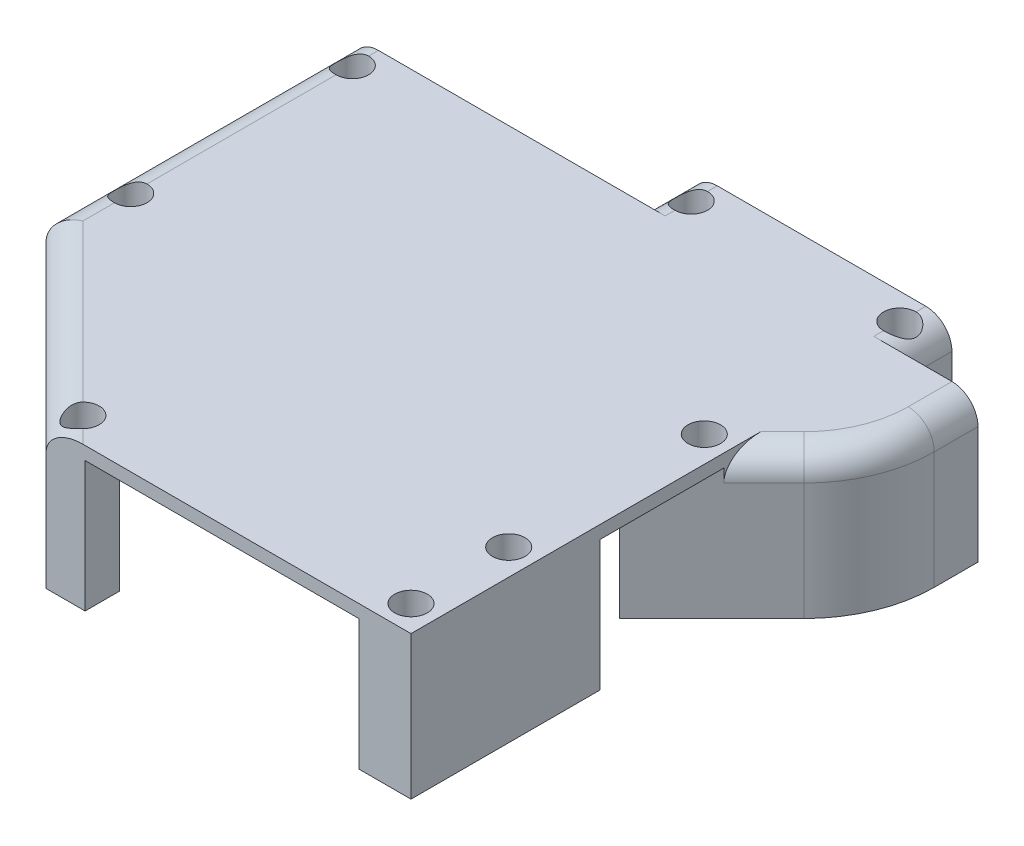
from build123d import *

# Parameters (mm, degrees)
BOSS_EXTRUDE2_DEPTH   = 11
BOSS_EXTRUDE2_2_DEPTH = 11
BOSS_EXTRUDE3_START   = 11
BOSS_EXTRUDE3_DEPTH   = 1
FILLET2_R             = 10
FILLET1_R             = 2
BOSS_EXTRUDE4_DEPTH   = 11
TUBE_HOLES_DEPTH      = 10
POT_INSERT_DEPTH      = 2.5
POT_START             = -2.5
SKETCH13_R            = 2.75
POT_HOLE_DEPTH        = 1.5
SKETCH7_R             = 0.8
SCREW_HOLES_DEPTH     = 12
SCREW_START           = 11
SKETCH12_R            = 1.25
SCREW_HEADS_DEPTH     = 3


with BuildPart() as part:
    # Sketch3 → Boss-Extrude2 (new body)
    with BuildSketch(Plane(origin=(0, 0, 0), x_dir=(1, 0, 0), z_dir=(0, 1, 0))):
        Polygon((-2.631461599, 29.291458176), (-6.631461599, 29.291458176), (-6.631461599, 5.791458176), (7.368538401, -8.208541824), (35.368538401, -8.208541824), (35.368538401, 15.791458176), (41.368538401, 21.791458176), (41.368538401, 29.291458179), (35.368538401, 29.291458179), (35.368538401, 33.291458176), (31.368538401, 33.291458176), (31.368538401, 29.291458176), (34.368538401, 29.291458176), (34.368538401, 28.291458176), (39.368538401, 28.291458176), (39.368538401, 22.619885301), (35.040111276, 18.291458176), (31.368538401, 18.291458176), (31.368538401, 11.791458176), (34.368538401, 14.791458176), (34.368538401, 5.306176806), (31.368538401, 2.306176806), (31.368538401, -0.708541824), (34.368538401, -0.708541824), (34.368538401, -4.208541824), (31.368538401, -4.208541824), (31.368538401, -7.208541824), (12.02539265, -7.208541824), (-2.631461599, 7.448312426), (-2.631461599, 12.291458176), (-5.631461599, 12.291458176), (-5.631461599, 25.291458176), (-2.631461599, 25.291458176), align=None)
    extrude(amount=BOSS_EXTRUDE2_DEPTH)



with BuildPart() as body_2:
    # Sketch3 → Boss-Extrude2 2 (new body)
    with BuildSketch(Plane(origin=(0, 0, 0), x_dir=(1, 0, 0), z_dir=(0, 1, 0))):
        Polygon((9.368538401, 29.291458176), (15.368538401, 29.291458176), (15.368538401, 33.291458176), (19.368538401, 33.291458176), (19.368538401, 28.291458176), (9.368538401, 28.291458176), align=None)
    extrude(amount=BOSS_EXTRUDE2_2_DEPTH)


with BuildPart() as part_1:
    add(part.part)

    add(body_2.part)  # Boss-Extrude3 merges body 2
    # Sketch5 → Boss-Extrude3 (add)
    with BuildSketch(Plane(origin=(0, 0, 0), x_dir=(1, 0, 0), z_dir=(0, 1, 0)).offset(BOSS_EXTRUDE3_START)):
        Polygon((-6.631461599, 29.291458176), (15.368538401, 29.291458176), (15.368538401, 33.291458176), (35.368538401, 33.291458176), (35.368538401, 29.291458179), (41.368538401, 29.291458179), (41.368538401, 21.791458176), (35.368538401, 15.791458176), (35.368538401, -8.208541824), (7.368538401, -8.208541824), (-6.631461599, 5.791458176), align=None)
    extrude(amount=-BOSS_EXTRUDE3_DEPTH)

    # Fillet2
    fillet2_edges = [part_1.edges().sort_by_distance(p)[0] for p in [
        (41.368538401, 5.5, -21.791458176),
    ]]
    fillet(fillet2_edges, radius=FILLET2_R)

    # Fillet1
    fillet1_edges = [part_1.edges().sort_by_distance(p)[0] for p in [
        (36.904072307, 11, -17.326992082),
        (41.368538401, 11, -27.61252599),
        (35.368538401, 11, -31.291458178),
        (15.368538401, 11, -31.291458176),
        (40.607333726, 11, -22.106759476),
        (-6.631461599, 11, -17.541458176),
        (0.368538401, 11, 1.208541824),
    ]]
    fillet(fillet1_edges, radius=FILLET1_R)

    # Sketch14 → Boss-Extrude4 (add)
    with BuildSketch(Plane(origin=(0, 0, 0), x_dir=(1, 0, 0), z_dir=(0, 1, 0))):
        Polygon((31.368538401, 11.791458176), (35.368538401, 15.791458176), (35.368538401, 17.791458176), (31.368538401, 13.791458176), align=None)
    extrude(amount=BOSS_EXTRUDE4_DEPTH)

    # Sketch10 → Tube Holes (cut)
    with BuildSketch(Plane(origin=(0, 0, 0), x_dir=(1, 0, 0), z_dir=(0, 1, 0))):
        Polygon((34.368538401, 5.306176806), (35.368538401, 6.306176806), (35.368538401, 15.791458176), (34.368538401, 14.791458176), align=None)
        Polygon((10.368538401, -5.551687574), (10.368538401, -8.208541824), (31.368538401, -8.208541824), (31.368538401, -3.516153668), (17.52539265, -3.516153668), (6.918790933, 7.09044805), (2.322596855, 2.494253972), align=None)
    extrude(amount=TUBE_HOLES_DEPTH, mode=Mode.SUBTRACT)

    # Sketch9 → Pot Insert (cut)
    with BuildSketch(Plane(origin=(-0.420001711, 0, 0.420001711), x_dir=(0.707106781, 0, 0.707106781), z_dir=(-0.707106781, 0, 0.707106781))):
        Polygon((-8.284330815, 0), (-8.284330815, -1.5), (-6.784330815, -4.5), (-6.784330815, -5.5), (-2.784330815, -5.5), (1.465669185, -5.5), (1.465669185, -4.5), (6.715669185, -4.5), (6.715669185, 0), align=None)
        Polygon((-8.284330815, 1.5), (-8.284330815, 0), (6.715669185, 0), (6.715669185, 4.5), (1.465669185, 4.5), (1.465669185, 5.5), (-2.784330815, 5.5), (-6.784330815, 5.5), (-6.784330815, 4.5), align=None)
    extrude(amount=-POT_INSERT_DEPTH, mode=Mode.SUBTRACT)

    # Sketch13 → Pot Hole (cut)
    with BuildSketch(Plane(origin=(-0.420001711, 0, 0.420001711), x_dir=(0.707106781, 0, 0.707106781), z_dir=(-0.707106781, 0, 0.707106781)).offset(POT_START)):
        with Locations((-2.784330815, 0)):
            Circle(SKETCH13_R)
        Polygon((6.715669185, 0), (6.715669185, 2.5), (4.715669185, 2.5), (4.715669185, -2.5), (6.715669185, -2.5), align=None)
    extrude(amount=-POT_HOLE_DEPTH, mode=Mode.SUBTRACT)

    # Sketch7 → Screw Holes (cut, through all)
    with BuildSketch(Plane(origin=(0, 0, 0), x_dir=(1, 0, 0), z_dir=(0, 1, 0))):
        with Locations((-4.631461599, 27.291458176)):
            Circle(SKETCH7_R)
        with Locations((17.368538401, 31.291458176)):
            Circle(SKETCH7_R)
        with Locations((33.368538401, 31.291458176)):
            Circle(SKETCH7_R)
        with Locations((-4.631461599, 10.291458176)):
            Circle(SKETCH7_R)
        with Locations((33.368538401, 16.291458176)):
            Circle(SKETCH7_R)
        with Locations((8.282751963, -6.294328261)):
            Circle(SKETCH7_R)
        with Locations((33.368538401, 1.291458176)):
            Circle(SKETCH7_R)
        with Locations((33.368538401, -6.208541824)):
            Circle(SKETCH7_R)
    extrude(amount=SCREW_HOLES_DEPTH, mode=Mode.SUBTRACT)

    # Sketch12 → Screw Heads (cut)
    with BuildSketch(Plane(origin=(0, 0, 0), x_dir=(1, 0, 0), z_dir=(0, 1, 0)).offset(SCREW_START)):
        with Locations((-4.631461599, 27.291458176)):
            Circle(SKETCH12_R)
        with Locations((17.368538401, 31.291458176)):
            Circle(SKETCH12_R)
        with Locations((33.368538401, 31.291458176)):
            Circle(SKETCH12_R)
        with Locations((-4.631461599, 10.291458176)):
            Circle(SKETCH12_R)
        with Locations((33.368538401, 16.291458176)):
            Circle(SKETCH12_R)
        with Locations((8.282751963, -6.294328261)):
            Circle(SKETCH12_R)
        with Locations((33.368538401, 1.291458176)):
            Circle(SKETCH12_R)
        with Locations((33.368538401, -6.208541824)):
            Circle(SKETCH12_R)
    extrude(amount=-SCREW_HEADS_DEPTH, mode=Mode.SUBTRACT)


solid = part_1.part
